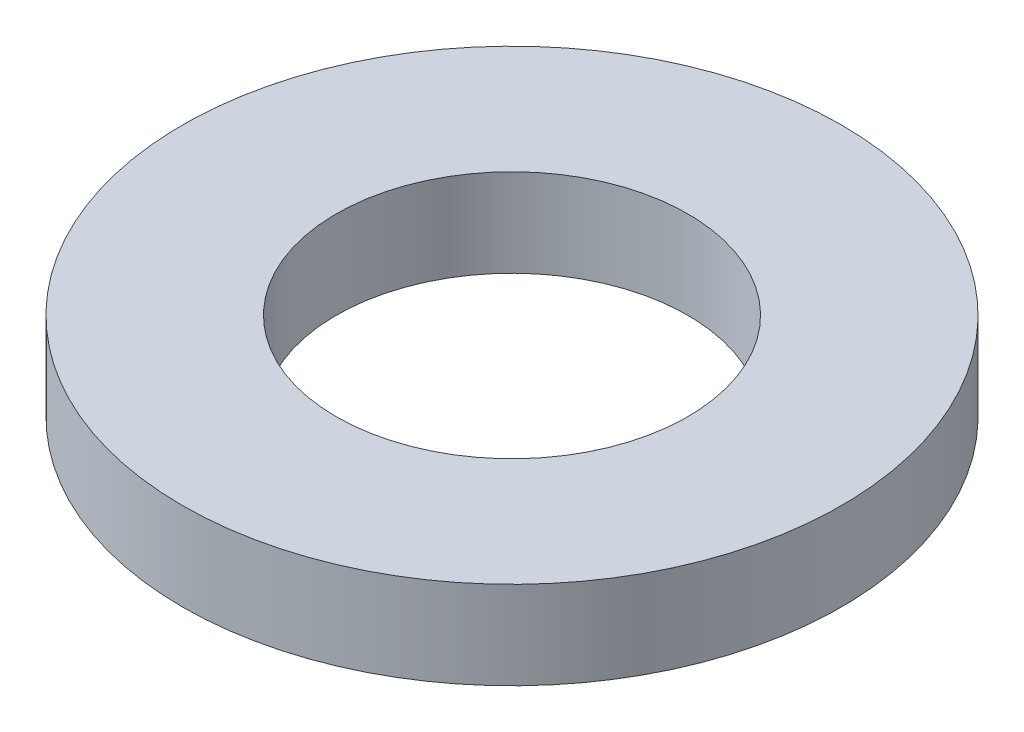
from build123d import *

# Parameters (mm, degrees)
CROQUIS1_R              = 7.5
SALIENTE_EXTRUIR1_DEPTH = 2
CROQUIS2_R              = 4
CORTAR_EXTRUIR1_DEPTH   = 3


with BuildPart() as part:
    # Croquis1 → Saliente-Extruir1 (new body)
    with BuildSketch(Plane(origin=(0, 0, 0), x_dir=(1, 0, 0), z_dir=(0, 1, 0))):
        Circle(CROQUIS1_R)
    extrude(amount=SALIENTE_EXTRUIR1_DEPTH)

    # Croquis2 → Cortar-Extruir1 (cut, through all)
    with BuildSketch(Plane(origin=(0, 0, 0), x_dir=(1, 0, 0), z_dir=(0, 1, 0))):
        Circle(CROQUIS2_R)
    extrude(amount=CORTAR_EXTRUIR1_DEPTH, mode=Mode.SUBTRACT)


solid = part.part
